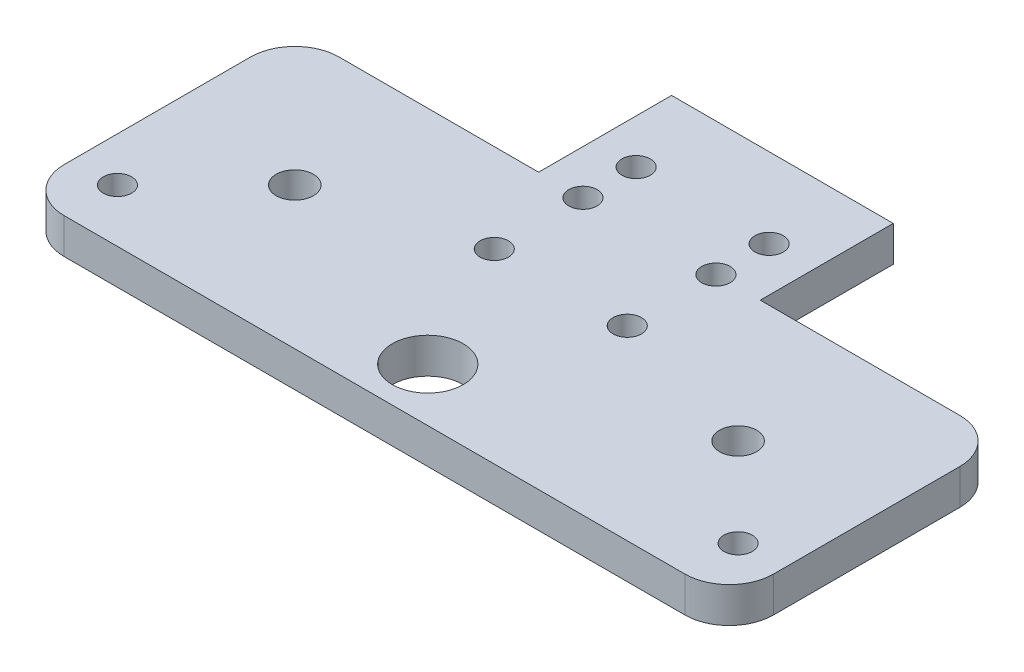
from build123d import *

# Parameters (mm, degrees)
SKETCH1_R           = 1.6
SKETCH1_R_2         = 2.1
SKETCH1_R_3         = 4
BOSS_EXTRUDE1_DEPTH = 4


with BuildPart() as part:
    # Sketch1 → Boss-Extrude1 (new body)
    with BuildSketch(Plane(origin=(0, 0, 0), x_dir=(1, 0, 0), z_dir=(0, 1, 0))):
        with BuildLine():
            Line((-35, -26), (35, -26))
            ThreePointArc((35, -26), (38.535533906, -24.535533906), (40, -21))
            Line((40, -21), (40, 0))
            ThreePointArc((40, 0), (38.535533906, 3.535533906), (35, 5))
            Line((35, 5), (12.5, 5))
            Line((12.5, 5), (12.5, 20))
            Line((12.5, 20), (-12.5, 20))
            Line((-12.5, 20), (-12.5, 5))
            Line((-12.5, 5), (-35, 5))
            ThreePointArc((-35, 5), (-38.535533906, 3.535533906), (-40, 0))
            Line((-40, 0), (-40, -21))
            ThreePointArc((-40, -21), (-38.535533906, -24.535533906), (-35, -26))
        make_face()
        with Locations((-7.5, 11)):
            Circle(SKETCH1_R, mode=Mode.SUBTRACT)
        with Locations((7.5, 11)):
            Circle(SKETCH1_R, mode=Mode.SUBTRACT)
        with Locations((-7.5, -5)):
            Circle(SKETCH1_R, mode=Mode.SUBTRACT)
        with Locations((7.5, -5)):
            Circle(SKETCH1_R, mode=Mode.SUBTRACT)
        with Locations((-7.5, 5)):
            Circle(SKETCH1_R, mode=Mode.SUBTRACT)
        with Locations((7.5, 5)):
            Circle(SKETCH1_R, mode=Mode.SUBTRACT)
        with Locations((-35, -20)):
            Circle(SKETCH1_R, mode=Mode.SUBTRACT)
        with Locations((35, -20)):
            Circle(SKETCH1_R, mode=Mode.SUBTRACT)
        with Locations((-25, -10)):
            Circle(SKETCH1_R_2, mode=Mode.SUBTRACT)
        with Locations((25, -10)):
            Circle(SKETCH1_R_2, mode=Mode.SUBTRACT)
        with Locations((0, -20)):
            Circle(SKETCH1_R_3, mode=Mode.SUBTRACT)
    extrude(amount=BOSS_EXTRUDE1_DEPTH)


solid = part.part
